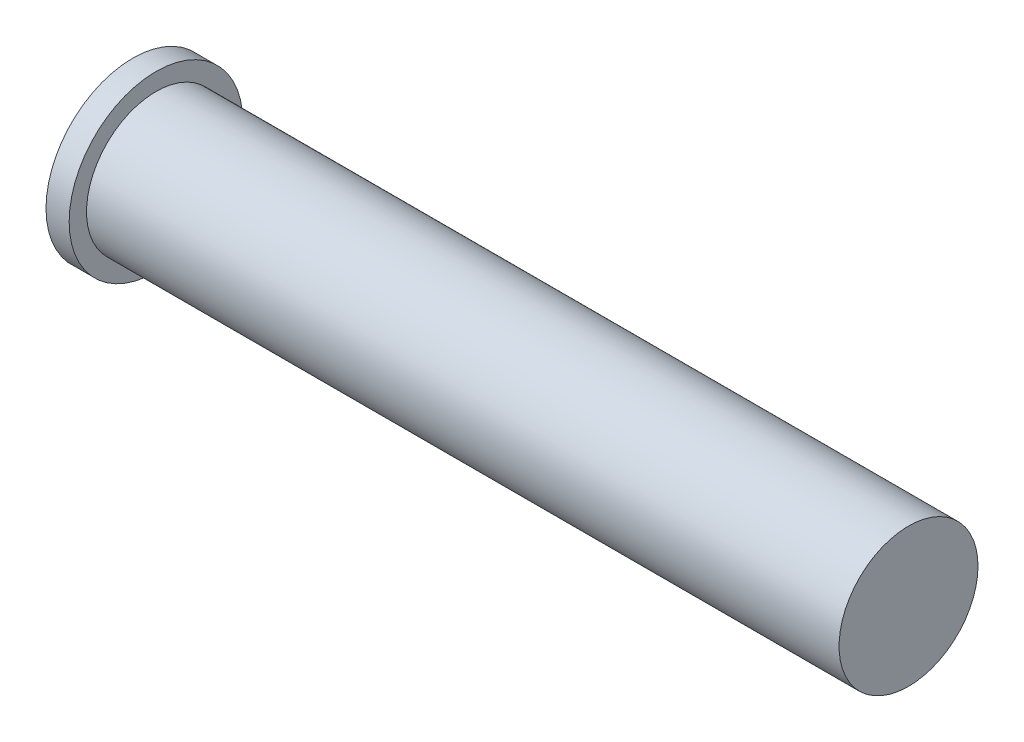
from build123d import *

# Parameters (mm, degrees)
SKETCH1_R           = 7.5
SKETCH1_R_2         = 6
BOSS_EXTRUDE2_DEPTH = 2
SKETCH1_4_R         = 6
BOSS_EXTRUDE3_DEPTH = 67


with BuildPart() as part:
    # Sketch1 → Boss-Extrude2 (new body)
    with BuildSketch(Plane(origin=(0, 0, 0), x_dir=(0, 0, -1), z_dir=(1, 0, 0))):
        Circle(SKETCH1_R)
        Circle(SKETCH1_R_2, mode=Mode.SUBTRACT)
    extrude(amount=BOSS_EXTRUDE2_DEPTH)

    # Sketch1_4 → Boss-Extrude3 (add)
    with BuildSketch(Plane(origin=(0, 0, 0), x_dir=(0, 0, -1), z_dir=(1, 0, 0))):
        Circle(SKETCH1_4_R)
    extrude(amount=BOSS_EXTRUDE3_DEPTH)


solid = part.part
